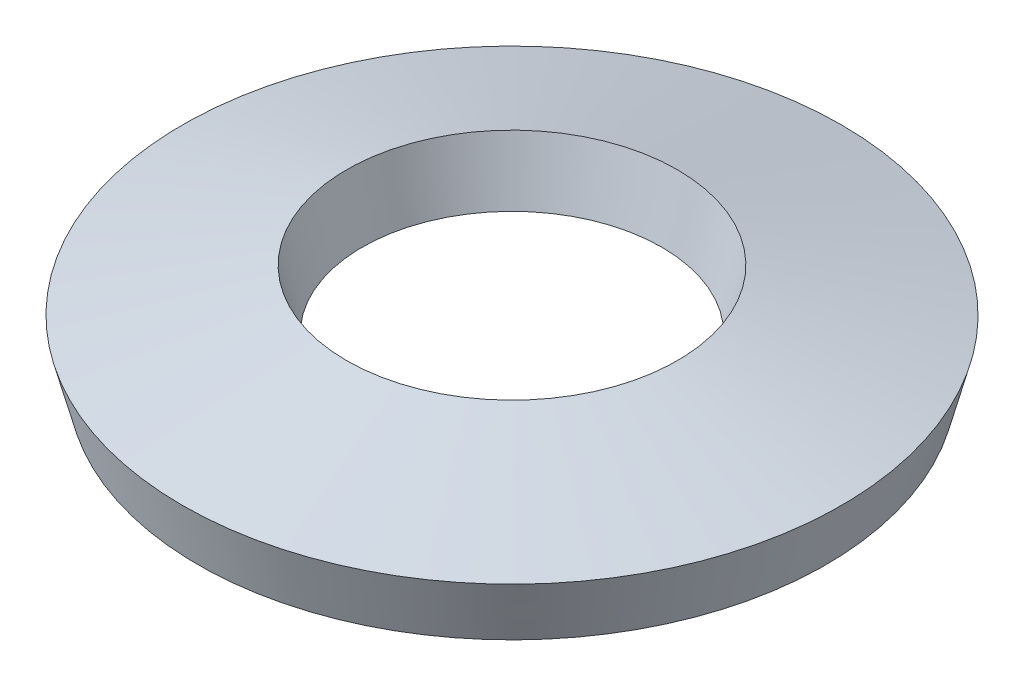
from build123d import *


with BuildPart() as part:
    # Sketch1 → Revolve1 (revolve)
    with BuildSketch(Plane.XY):
        Polygon((6.762507097, 0), (3.2258, 0.932661331), (3.562592903, 2.2098), (7.0993, 1.277138669), align=None)
    revolve(axis=Axis((0, 0, 0), (0, 1, 0)))


solid = part.part
